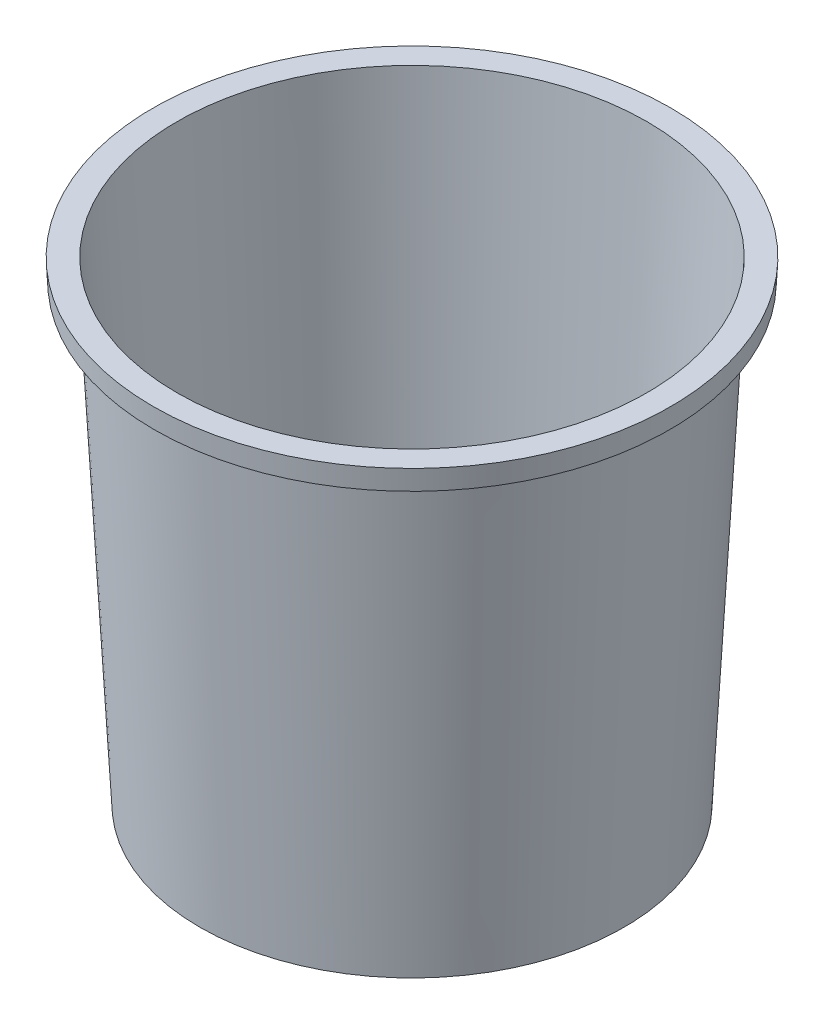
from build123d import *

# Parameters (mm, degrees)
SKETCH1_R           = 102.9
BOSS_EXTRUDE1_DEPTH = 230
BOSS_EXTRUDE1_DRAFT = -3
SHELL2_T            = -1


with BuildPart() as part:
    # Sketch1 → Boss-Extrude1 (with draft: the straight prism first)
    with BuildSketch(Plane(origin=(0, 0, 0), x_dir=(1, 0, 0), z_dir=(0, 1, 0))):
        Circle(SKETCH1_R)
    extrude(amount=BOSS_EXTRUDE1_DEPTH)
    # Boss-Extrude1: the draft: its side faces are tilted about the plane it starts from
    boss_extrude1_sides = [part.faces().sort_by_distance(p)[0] for p in [
        (-102.9, 115, 0),
    ]]
    draft(boss_extrude1_sides, Plane(origin=(0, 0, 0), x_dir=(1, 0, 0), z_dir=(0, 1, 0)), BOSS_EXTRUDE1_DRAFT)

    # Shell2
    shell2_openings = [part.faces().sort_by_distance(p)[0] for p in [
        (0, 230, 0),
    ]]
    offset(amount=SHELL2_T, openings=shell2_openings, kind=Kind.INTERSECTION)

    # Sketch4 → Revolve2 (revolve)
    with BuildSketch(Plane.XY, mode=Mode.PRIVATE) as revolve2_sk:
        Polygon((114.953789235, 230), (125.477867028, 230), (124.953789235, 220), (122.849117323, 220), (123.268523203, 228.00274093), (114.849117323, 228.00274093), align=None)
    revolve(revolve2_sk.sketch.rotate(Axis((0, 230, 0), (0, -1, 0)), 90), axis=Axis((0, 230, 0), (0, -1, 0)))


solid = part.part
